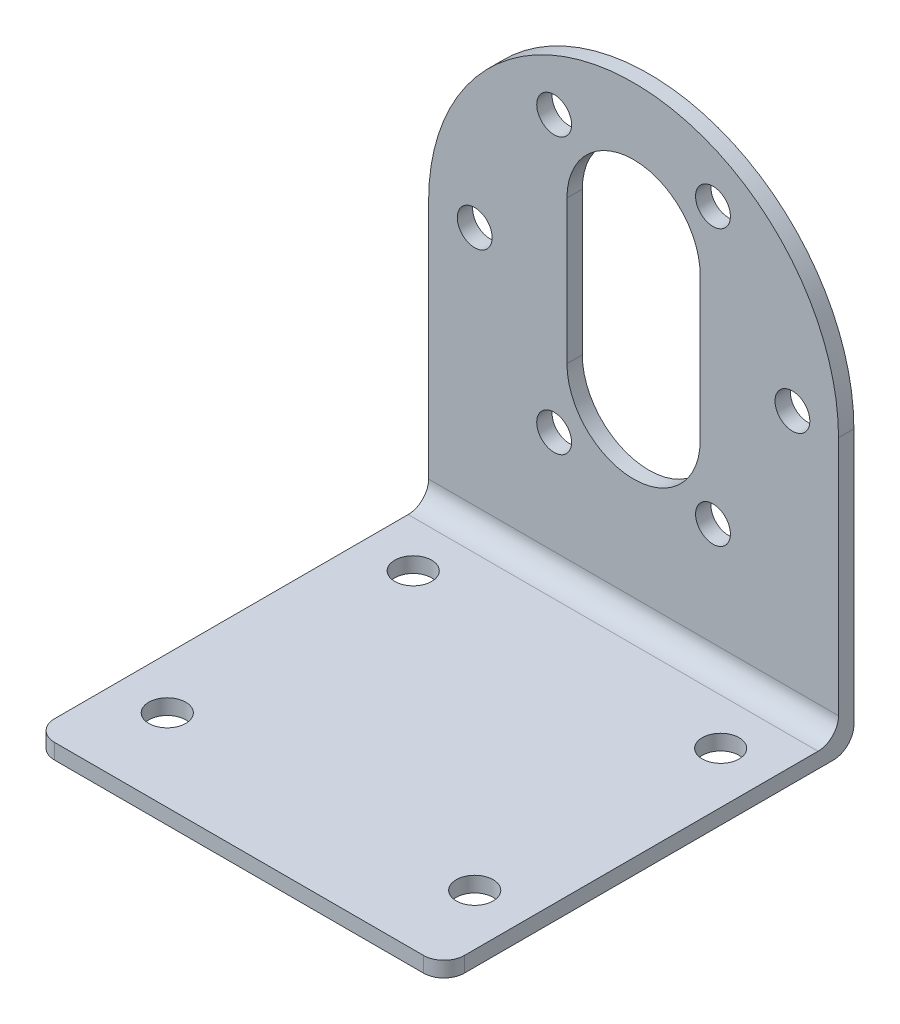
from build123d import *

# Parameters (mm, degrees)
SKETCH1_W           = 40
SKETCH1_H           = 40
BOSS_EXTRUDE1_DEPTH = 1.5
SKETCH2_W           = 40
SKETCH2_H           = 1.5
BOSS_EXTRUDE2_DEPTH = 45.5
CUT_EXTRUDE2_REACH  = 75.546
CUT_EXTRUDE3_REACH  = 75.546
SKETCH4_R           = 1.7
CUT_EXTRUDE4_REACH  = 74.596
SKETCH5_R           = 1.8
FILLET1_R           = 2


with BuildPart() as part:
    # Sketch1 → Boss-Extrude1 (new body)
    with BuildSketch(Plane(origin=(0, 0, 0), x_dir=(1, 0, 0), z_dir=(0, 1, 0))):
        with Locations((20, 20)):
            Rectangle(SKETCH1_W, SKETCH1_H)
    extrude(amount=BOSS_EXTRUDE1_DEPTH)

    # Sketch2 → Boss-Extrude2 (add)
    with BuildSketch(Plane(origin=(0, 1.5, 0), x_dir=(1, 0, 0), z_dir=(0, 1, 0))):
        with Locations((20, 39.25)):
            Rectangle(SKETCH2_W, SKETCH2_H)
    extrude(amount=BOSS_EXTRUDE2_DEPTH)

    # Sketch3 → Cut-Extrude2 (cut, up to next)
    with BuildSketch(Plane(origin=(0, 0, -40), x_dir=(-1, 0, 0), z_dir=(0, 0, -1)), mode=Mode.PRIVATE) as cut_extrude2_sk1:
        with BuildLine():
            Line((-13.5, 20), (-13.5, 34))
            ThreePointArc((-13.5, 34), (-20, 40.5), (-26.5, 34))
            Line((-26.5, 34), (-26.5, 20))
            ThreePointArc((-26.5, 20), (-20, 13.5), (-13.5, 20))
        make_face()
    cut_extrude2_tool1 = extrude(cut_extrude2_sk1.sketch, amount=-CUT_EXTRUDE2_REACH, mode=Mode.PRIVATE) & part.part
    # Sketch3 → Cut-Extrude2 (cut, up to next)
    with BuildSketch(Plane(origin=(0, 0, -40), x_dir=(-1, 0, 0), z_dir=(0, 0, -1)), mode=Mode.PRIVATE) as cut_extrude2_sk2:
        with BuildLine():
            Line((-20, 47), (-40, 47))
            Line((-40, 47), (-40, 27))
            ThreePointArc((-40, 27), (-34.142135624, 41.142135624), (-20, 47))
        make_face()
    cut_extrude2_tool2 = extrude(cut_extrude2_sk2.sketch, amount=-CUT_EXTRUDE2_REACH, mode=Mode.PRIVATE) & part.part
    # Sketch3 → Cut-Extrude2 (cut, up to next)
    with BuildSketch(Plane(origin=(0, 0, -40), x_dir=(-1, 0, 0), z_dir=(0, 0, -1)), mode=Mode.PRIVATE) as cut_extrude2_sk3:
        with BuildLine():
            Line((0, 47), (-20, 47))
            ThreePointArc((-20, 47), (-5.857864376, 41.142135624), (0, 27))
            Line((0, 27), (0, 47))
        make_face()
    cut_extrude2_tool3 = extrude(cut_extrude2_sk3.sketch, amount=-CUT_EXTRUDE2_REACH, mode=Mode.PRIVATE) & part.part
    add(cut_extrude2_tool1.solids().sort_by_distance((20, 27, -40))[0], mode=Mode.SUBTRACT)
    add(cut_extrude2_tool2.solids().sort_by_distance((35.532641, 42.532641, -40))[0], mode=Mode.SUBTRACT)
    add(cut_extrude2_tool3.solids().sort_by_distance((4.467359, 42.532641, -40))[0], mode=Mode.SUBTRACT)

    # Sketch4 → Cut-Extrude3 (cut, up to next)
    with BuildSketch(Plane(origin=(0, 0, -40), x_dir=(-1, 0, 0), z_dir=(0, 0, -1)), mode=Mode.PRIVATE) as cut_extrude3_sk1:
        with Locations((-35.5, 27)):
            Circle(SKETCH4_R)
    cut_extrude3_tool1 = extrude(cut_extrude3_sk1.sketch, amount=-CUT_EXTRUDE3_REACH, mode=Mode.PRIVATE) & part.part
    # Sketch4 → Cut-Extrude3 (cut, up to next)
    with BuildSketch(Plane(origin=(0, 0, -40), x_dir=(-1, 0, 0), z_dir=(0, 0, -1)), mode=Mode.PRIVATE) as cut_extrude3_sk2:
        with Locations((-27.75, 40.423393759)):
            Circle(SKETCH4_R)
    cut_extrude3_tool2 = extrude(cut_extrude3_sk2.sketch, amount=-CUT_EXTRUDE3_REACH, mode=Mode.PRIVATE) & part.part
    # Sketch4 → Cut-Extrude3 (cut, up to next)
    with BuildSketch(Plane(origin=(0, 0, -40), x_dir=(-1, 0, 0), z_dir=(0, 0, -1)), mode=Mode.PRIVATE) as cut_extrude3_sk3:
        with Locations((-12.25, 40.423393759)):
            Circle(SKETCH4_R)
    cut_extrude3_tool3 = extrude(cut_extrude3_sk3.sketch, amount=-CUT_EXTRUDE3_REACH, mode=Mode.PRIVATE) & part.part
    # Sketch4 → Cut-Extrude3 (cut, up to next)
    with BuildSketch(Plane(origin=(0, 0, -40), x_dir=(-1, 0, 0), z_dir=(0, 0, -1)), mode=Mode.PRIVATE) as cut_extrude3_sk4:
        with Locations((-4.5, 27)):
            Circle(SKETCH4_R)
    cut_extrude3_tool4 = extrude(cut_extrude3_sk4.sketch, amount=-CUT_EXTRUDE3_REACH, mode=Mode.PRIVATE) & part.part
    # Sketch4 → Cut-Extrude3 (cut, up to next)
    with BuildSketch(Plane(origin=(0, 0, -40), x_dir=(-1, 0, 0), z_dir=(0, 0, -1)), mode=Mode.PRIVATE) as cut_extrude3_sk5:
        with Locations((-12.25, 13.576606241)):
            Circle(SKETCH4_R)
    cut_extrude3_tool5 = extrude(cut_extrude3_sk5.sketch, amount=-CUT_EXTRUDE3_REACH, mode=Mode.PRIVATE) & part.part
    # Sketch4 → Cut-Extrude3 (cut, up to next)
    with BuildSketch(Plane(origin=(0, 0, -40), x_dir=(-1, 0, 0), z_dir=(0, 0, -1)), mode=Mode.PRIVATE) as cut_extrude3_sk6:
        with Locations((-27.75, 13.576606241)):
            Circle(SKETCH4_R)
    cut_extrude3_tool6 = extrude(cut_extrude3_sk6.sketch, amount=-CUT_EXTRUDE3_REACH, mode=Mode.PRIVATE) & part.part
    add(cut_extrude3_tool1.solids().sort_by_distance((35.5, 27, -40))[0], mode=Mode.SUBTRACT)
    add(cut_extrude3_tool2.solids().sort_by_distance((27.75, 40.423394, -40))[0], mode=Mode.SUBTRACT)
    add(cut_extrude3_tool3.solids().sort_by_distance((12.25, 40.423394, -40))[0], mode=Mode.SUBTRACT)
    add(cut_extrude3_tool4.solids().sort_by_distance((4.5, 27, -40))[0], mode=Mode.SUBTRACT)
    add(cut_extrude3_tool5.solids().sort_by_distance((12.25, 13.576606, -40))[0], mode=Mode.SUBTRACT)
    add(cut_extrude3_tool6.solids().sort_by_distance((27.75, 13.576606, -40))[0], mode=Mode.SUBTRACT)

    # Sketch5 → Cut-Extrude4 (cut, up to next)
    with BuildSketch(Plane(origin=(0, 1.5, 0), x_dir=(1, 0, 0), z_dir=(0, 1, 0)), mode=Mode.PRIVATE) as cut_extrude4_sk1:
        with Locations(Location((5, 32, 0), (0, 0, 270))):
            Circle(SKETCH5_R)
    cut_extrude4_tool1 = extrude(cut_extrude4_sk1.sketch, amount=-CUT_EXTRUDE4_REACH, mode=Mode.PRIVATE) & part.part
    # Sketch5 → Cut-Extrude4 (cut, up to next)
    with BuildSketch(Plane(origin=(0, 1.5, 0), x_dir=(1, 0, 0), z_dir=(0, 1, 0)), mode=Mode.PRIVATE) as cut_extrude4_sk2:
        with Locations(Location((35, 32, 0), (0, 0, 270))):
            Circle(SKETCH5_R)
    cut_extrude4_tool2 = extrude(cut_extrude4_sk2.sketch, amount=-CUT_EXTRUDE4_REACH, mode=Mode.PRIVATE) & part.part
    # Sketch5 → Cut-Extrude4 (cut, up to next)
    with BuildSketch(Plane(origin=(0, 1.5, 0), x_dir=(1, 0, 0), z_dir=(0, 1, 0)), mode=Mode.PRIVATE) as cut_extrude4_sk3:
        with Locations(Location((35, 8, 0), (0, 0, 270))):
            Circle(SKETCH5_R)
    cut_extrude4_tool3 = extrude(cut_extrude4_sk3.sketch, amount=-CUT_EXTRUDE4_REACH, mode=Mode.PRIVATE) & part.part
    # Sketch5 → Cut-Extrude4 (cut, up to next)
    with BuildSketch(Plane(origin=(0, 1.5, 0), x_dir=(1, 0, 0), z_dir=(0, 1, 0)), mode=Mode.PRIVATE) as cut_extrude4_sk4:
        with Locations(Location((5, 8, 0), (0, 0, 270))):
            Circle(SKETCH5_R)
    cut_extrude4_tool4 = extrude(cut_extrude4_sk4.sketch, amount=-CUT_EXTRUDE4_REACH, mode=Mode.PRIVATE) & part.part
    add(cut_extrude4_tool1.solids().sort_by_distance((5, 1.5, -32))[0], mode=Mode.SUBTRACT)
    add(cut_extrude4_tool2.solids().sort_by_distance((35, 1.5, -32))[0], mode=Mode.SUBTRACT)
    add(cut_extrude4_tool3.solids().sort_by_distance((35, 1.5, -8))[0], mode=Mode.SUBTRACT)
    add(cut_extrude4_tool4.solids().sort_by_distance((5, 1.5, -8))[0], mode=Mode.SUBTRACT)

    # Fillet1
    fillet1_edges = [part.edges().sort_by_distance(p)[0] for p in [
        (20, 1.5, -38.5),
        (20, 0, -40),
        (40, 0.75, 0),
        (0, 0.75, 0),
    ]]
    fillet(fillet1_edges, radius=FILLET1_R)


solid = part.part
